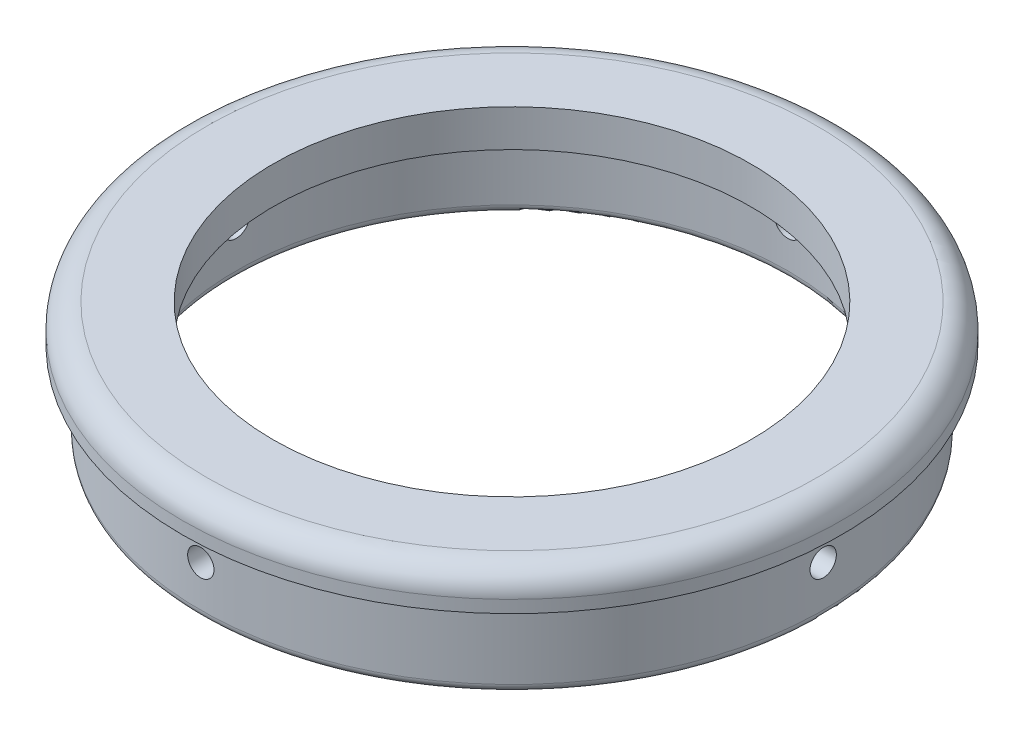
from build123d import *

# Parameters (mm, degrees)
SKETCH_1_R               = 40
SKETCH_1_R_2             = 29
EXTRUDE_1_DEPTH          = 4.5
SKETCH_2_R               = 37.8
SKETCH_2_R_2             = 33.5
EXTRUDE_2_DEPTH          = 10
FILLET_1_R               = 1
FILLET_2_R               = 3
SKETCH_3_R               = 1.6
CUT_EXTRUDE_1_DEPTH      = 41
CUT_EXTRUDE_1_DEPTH_BACK = 41.0000001
SKETCH_4_R               = 1.6
CUT_EXTRUDE_2_DEPTH      = 41
CUT_EXTRUDE_2_DEPTH_BACK = 41


with BuildPart() as part:
    # 草图1 → 凸台-拉伸1 (new body)
    with BuildSketch(Plane(origin=(0, 0, 0), x_dir=(1, 0, 0), z_dir=(0, 1, 0))):
        Circle(SKETCH_1_R)
        Circle(SKETCH_1_R_2, mode=Mode.SUBTRACT)
    extrude(amount=EXTRUDE_1_DEPTH)

    # 草图2 → 凸台-拉伸2 (add)
    with BuildSketch(Plane.XZ):
        Circle(SKETCH_2_R)
        Circle(SKETCH_2_R_2, mode=Mode.SUBTRACT)
    extrude(amount=EXTRUDE_2_DEPTH)

    # 圆角1
    fillet_1_edges = [part.edges().sort_by_distance(p)[0] for p in [
        (-37.8, -10, 0),
        (-33.5, -10, 0),
    ]]
    fillet(fillet_1_edges, radius=FILLET_1_R)

    # 圆角2
    fillet_2_edges = [part.edges().sort_by_distance(p)[0] for p in [
        (-40, 4.5, 0),
    ]]
    fillet(fillet_2_edges, radius=FILLET_2_R)

    # 草图3 → 切除-拉伸1 (cut, two sides)
    with BuildSketch(Plane(origin=(0, 0, 0), x_dir=(0, 0, -1), z_dir=(1, 0, 0))) as cut_extrude_1_sk:
        with Locations((0, -4)):
            Circle(SKETCH_3_R)
    extrude(amount=CUT_EXTRUDE_1_DEPTH, mode=Mode.SUBTRACT)
    extrude(cut_extrude_1_sk.sketch, amount=-CUT_EXTRUDE_1_DEPTH_BACK, mode=Mode.SUBTRACT)

    # 草图4 → 切除-拉伸2 (cut, two sides)
    with BuildSketch(Plane.XY) as cut_extrude_2_sk:
        with Locations((0, -4)):
            Circle(SKETCH_4_R)
    extrude(amount=CUT_EXTRUDE_2_DEPTH, mode=Mode.SUBTRACT)
    extrude(cut_extrude_2_sk.sketch, amount=-CUT_EXTRUDE_2_DEPTH_BACK, mode=Mode.SUBTRACT)


solid = part.part
